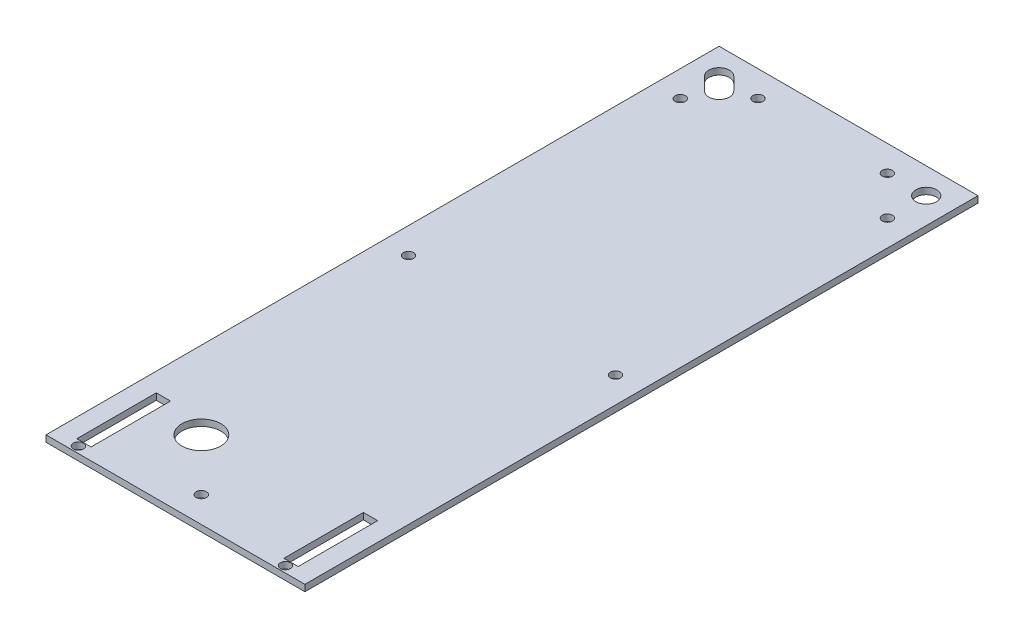
from build123d import *

# Parameters (mm, degrees)
SKETCH1_W           = 127
SKETCH1_H           = 330.2
BOSS_EXTRUDE1_DEPTH = 3.175
SKETCH2_R           = 2.5
SKETCH2_R_2         = 5.08
CUT_EXTRUDE1_DEPTH  = 25.4
SKETCH3_W           = 7
SKETCH3_H           = 39
SKETCH3_R           = 9.525
CUT_EXTRUDE2_DEPTH  = 25.4


with BuildPart() as part:
    # Sketch1 → Boss-Extrude1 (new body)
    with BuildSketch(Plane(origin=(0, 0, 0), x_dir=(1, 0, 0), z_dir=(0, 1, 0))):
        Rectangle(SKETCH1_W, SKETCH1_H)
    extrude(amount=BOSS_EXTRUDE1_DEPTH)

    # Sketch2 → Cut-Extrude1 (cut)
    # profile 1 of 14: a face of its own
    with BuildSketch(Plane(origin=(0, 3.175, 0), x_dir=(1, 0, 0), z_dir=(0, 1, 0))):
        with BuildLine():
            Line((-47.207897552, 155.992102448), (-40.857897552, 149.642102448))
            ThreePointArc((-40.857897552, 149.642102448), (-40.857897552, 142.457897552), (-48.042102448, 142.457897552))
            Line((-48.042102448, 142.457897552), (-54.392102448, 148.807897552))
            ThreePointArc((-54.392102448, 148.807897552), (-54.392102448, 155.992102448), (-47.207897552, 155.992102448))
        make_face()
        with Locations((-44.45, 146.05)):
            Circle(SKETCH2_R, mode=Mode.SUBTRACT)
        with Locations((-50.8, 152.4)):
            Circle(SKETCH2_R, mode=Mode.SUBTRACT)
    # profile 2 of 14: a face of its own
    with BuildSketch(Plane(origin=(0, 3.175, 0), x_dir=(1, 0, 0), z_dir=(0, 1, 0))):
        with Locations((-44.45, 146.05)):
            Circle(SKETCH2_R)
    # profile 3 of 14: a face of its own
    with BuildSketch(Plane(origin=(0, 3.175, 0), x_dir=(1, 0, 0), z_dir=(0, 1, 0))):
        with Locations((-50.8, 152.4)):
            Circle(SKETCH2_R)
    # profile 4 of 14: a face of its own
    with BuildSketch(Plane(origin=(0, 3.175, 0), x_dir=(1, 0, 0), z_dir=(0, 1, 0))):
        with Locations((50.8, 152.4)):
            Circle(SKETCH2_R_2)
        with Locations((50.8, 152.4)):
            Circle(SKETCH2_R, mode=Mode.SUBTRACT)
    # profile 5 of 14: a face of its own
    with BuildSketch(Plane(origin=(0, 3.175, 0), x_dir=(1, 0, 0), z_dir=(0, 1, 0))):
        with Locations((50.8, 152.4)):
            Circle(SKETCH2_R)
    # profile 6 of 14: a face of its own
    with BuildSketch(Plane(origin=(0, 3.175, 0), x_dir=(1, 0, 0), z_dir=(0, 1, 0))):
        with Locations((-31.75, 152.4)):
            Circle(SKETCH2_R)
    # profile 7 of 14: a face of its own
    with BuildSketch(Plane(origin=(0, 3.175, 0), x_dir=(1, 0, 0), z_dir=(0, 1, 0))):
        with Locations((31.75, 152.4)):
            Circle(SKETCH2_R)
    # profile 8 of 14: a face of its own
    with BuildSketch(Plane(origin=(0, 3.175, 0), x_dir=(1, 0, 0), z_dir=(0, 1, 0))):
        with Locations((-50.8, 133.35)):
            Circle(SKETCH2_R)
    # profile 9 of 14: a face of its own
    with BuildSketch(Plane(origin=(0, 3.175, 0), x_dir=(1, 0, 0), z_dir=(0, 1, 0))):
        with Locations((50.8, 133.35)):
            Circle(SKETCH2_R)
    # profile 10 of 14: a face of its own
    with BuildSketch(Plane(origin=(0, 3.175, 0), x_dir=(1, 0, 0), z_dir=(0, 1, 0))):
        with Locations((-50.8, -161.925)):
            Circle(SKETCH2_R)
    # profile 11 of 14: a face of its own
    with BuildSketch(Plane(origin=(0, 3.175, 0), x_dir=(1, 0, 0), z_dir=(0, 1, 0))):
        with Locations((50.8, -161.925)):
            Circle(SKETCH2_R)
    # profile 12 of 14: a face of its own
    with BuildSketch(Plane(origin=(0, 3.175, 0), x_dir=(1, 0, 0), z_dir=(0, 1, 0))):
        with Locations((-50.8, 0)):
            Circle(SKETCH2_R)
    # profile 13 of 14: a face of its own
    with BuildSketch(Plane(origin=(0, 3.175, 0), x_dir=(1, 0, 0), z_dir=(0, 1, 0))):
        with Locations((50.8, 0)):
            Circle(SKETCH2_R)
    # profile 14 of 14: a face of its own
    with BuildSketch(Plane(origin=(0, 3.175, 0), x_dir=(1, 0, 0), z_dir=(0, 1, 0))):
        with Locations((0, -152.4)):
            Circle(SKETCH2_R)
    extrude(amount=-CUT_EXTRUDE1_DEPTH, mode=Mode.SUBTRACT)

    # Sketch3 → Cut-Extrude2 (cut)
    with BuildSketch(Plane(origin=(0, 3.175, 0), x_dir=(1, 0, 0), z_dir=(0, 1, 0))):
        with Locations((-50.8, -139.7)):
            Rectangle(SKETCH3_W, SKETCH3_H)
        with Locations((50.8, -139.7)):
            Rectangle(SKETCH3_W, SKETCH3_H)
        with Locations((-25.4, -127)):
            Circle(SKETCH3_R)
    extrude(amount=-CUT_EXTRUDE2_DEPTH, mode=Mode.SUBTRACT)


solid = part.part
